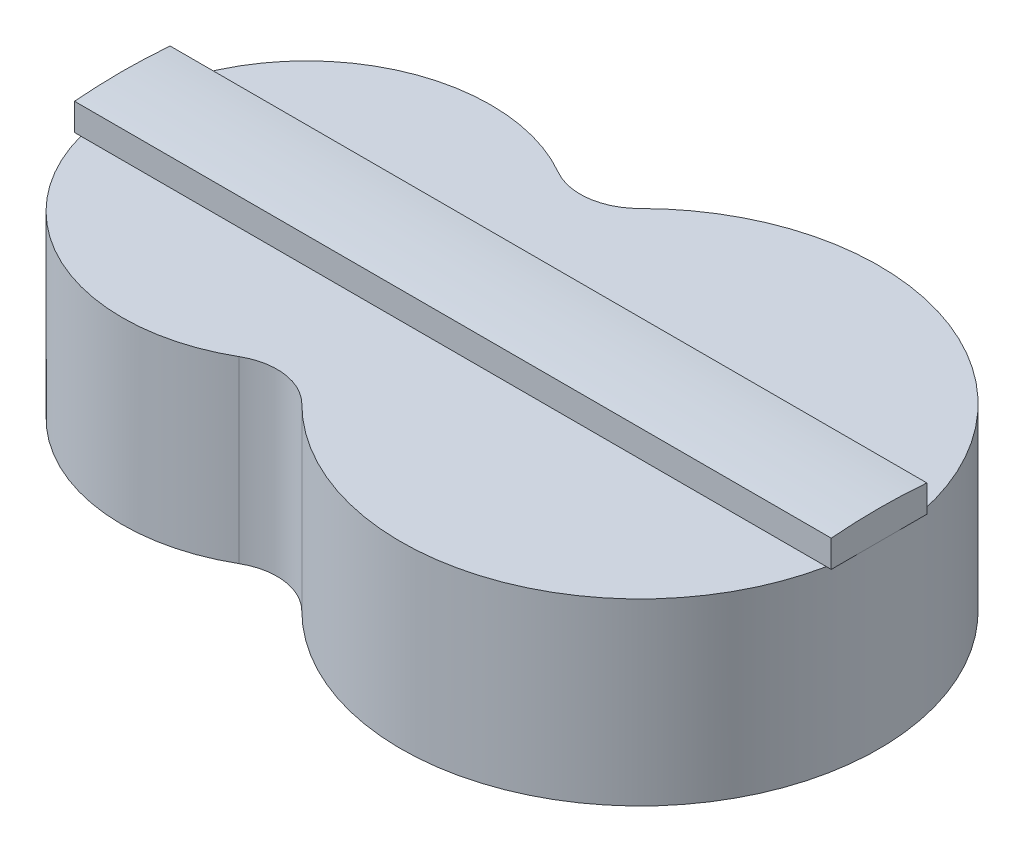
from build123d import *

# Parameters (mm, degrees)
BOSS_EXTRUDE3_DEPTH      = 75
BOSS_EXTRUDE4_DEPTH      = 100
BOSS_EXTRUDE4_DEPTH_BACK = 216.481457


with BuildPart() as part:
    # Sketch1 → Boss-Extrude3 (new body)
    with BuildSketch(Plane(origin=(0, 0, 0), x_dir=(1, 0, 0), z_dir=(0, 1, 0))):
        with BuildLine():
            ThreePointArc((-70.710678119, -70.710678119), (100, 0), (-70.710678119, 70.710678119))
            ThreePointArc((-70.710678119, 70.710678119), (-85.125192843, 63.602226114), (-100.888347648, 66.737712554))
            ThreePointArc((-100.888347648, 66.737712554), (-216.481456572, 0), (-100.888347648, -66.737712554))
            ThreePointArc((-100.888347648, -66.737712554), (-85.125192843, -63.602226114), (-70.710678119, -70.710678119))
        make_face()
    extrude(amount=-BOSS_EXTRUDE3_DEPTH)

    # Sketch6 → Boss-Extrude4 (add, two sides)
    with BuildSketch(Plane(origin=(0, 0, 0), x_dir=(0, 0, -1), z_dir=(1, 0, 0))) as boss_extrude4_sk:
        with BuildLine():
            Line((20, 0), (20, 11.326222077))
            ThreePointArc((20, 11.326222077), (0, 12.171), (-20, 11.326222077))
            Line((-20, 11.326222077), (-20, 0))
            Line((-20, 0), (20, 0))
        make_face()
    extrude(amount=BOSS_EXTRUDE4_DEPTH)
    extrude(boss_extrude4_sk.sketch, amount=-BOSS_EXTRUDE4_DEPTH_BACK)


solid = part.part
